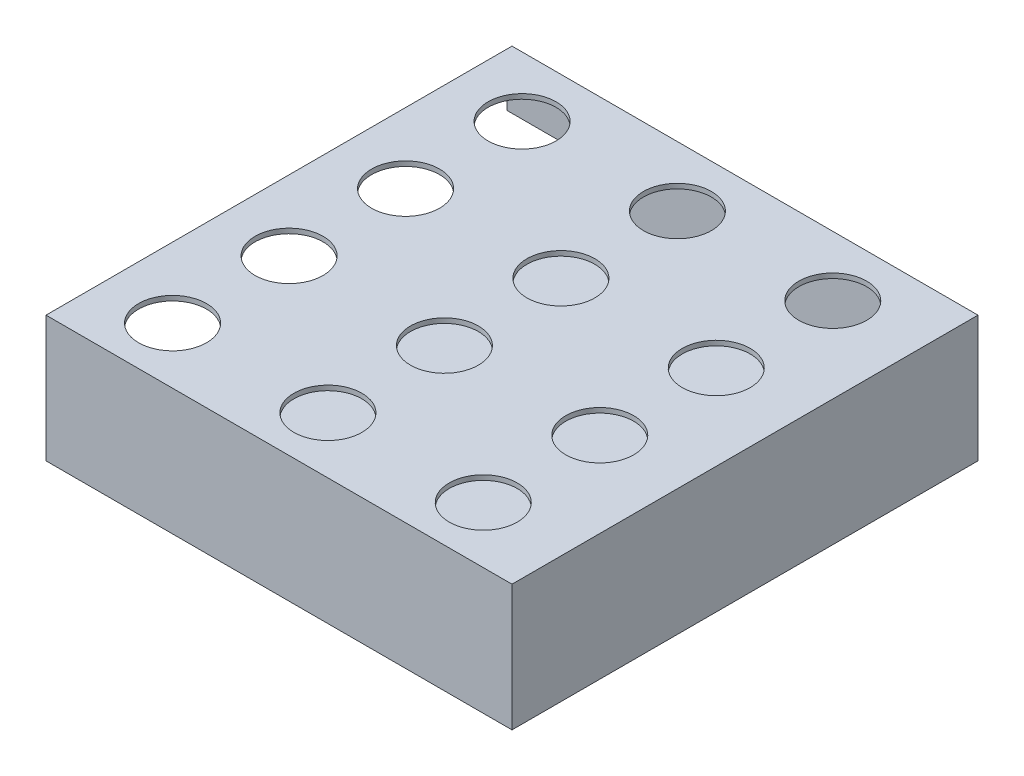
from build123d import *

# Parameters (mm, degrees)
SKETCH1_W           = 609.6
SKETCH1_H           = 165.1
BOSS_EXTRUDE1_DEPTH = 609.6
SHELL1_T            = -6.35
SKETCH2_R           = 44.45
CUT_EXTRUDE2_DEPTH  = 7.62
SKETCH4_W           = 88.9
SKETCH4_H           = 88.9
CUT_EXTRUDE3_DEPTH  = 7.62


with BuildPart() as part:
    # Sketch1 → Boss-Extrude1 (new body)
    with BuildSketch(Plane.XY):
        Rectangle(SKETCH1_W, SKETCH1_H)
    extrude(amount=-BOSS_EXTRUDE1_DEPTH)

    # Shell1
    shell1_openings = [part.faces().sort_by_distance(p)[0] for p in [
        (-304.8, 0, -304.8),
    ]]
    offset(amount=SHELL1_T, openings=shell1_openings, kind=Kind.INTERSECTION)

    # Sketch2 → Cut-Extrude2 (cut)
    with BuildSketch(Plane(origin=(0, 82.55, 0), x_dir=(1, 0, 0), z_dir=(0, 1, 0))):
        with Locations((-212.941456521, 378.528168367)):
            Circle(SKETCH2_R)
        with Locations((-212.941456521, 226.128168367)):
            Circle(SKETCH2_R)
        with Locations((-212.941456521, 73.728168367)):
            Circle(SKETCH2_R)
        with Locations((-9.741456521, 226.128168367)):
            Circle(SKETCH2_R)
        with Locations((-9.741456521, 378.528168367)):
            Circle(SKETCH2_R)
        with Locations((-9.741456521, 73.728168367)):
            Circle(SKETCH2_R)
        with Locations((193.458543479, 226.128168367)):
            Circle(SKETCH2_R)
        with Locations((193.458543479, 378.528168367)):
            Circle(SKETCH2_R)
        with Locations((193.458543479, 73.728168367)):
            Circle(SKETCH2_R)
        with Locations((-212.941456521, 530.928168367)):
            Circle(SKETCH2_R)
        with Locations((-9.741456521, 530.928168367)):
            Circle(SKETCH2_R)
        with Locations((193.458543479, 530.928168367)):
            Circle(SKETCH2_R)
    extrude(amount=-CUT_EXTRUDE2_DEPTH, mode=Mode.SUBTRACT)

    # Sketch4 → Cut-Extrude3 (cut)
    with BuildSketch(Plane(origin=(0, 0, -609.6), x_dir=(-1, 0, 0), z_dir=(0, 0, -1))):
        with Locations((260.35, -31.75)):
            Rectangle(SKETCH4_W, SKETCH4_H)
    extrude(amount=-CUT_EXTRUDE3_DEPTH, mode=Mode.SUBTRACT)


solid = part.part
